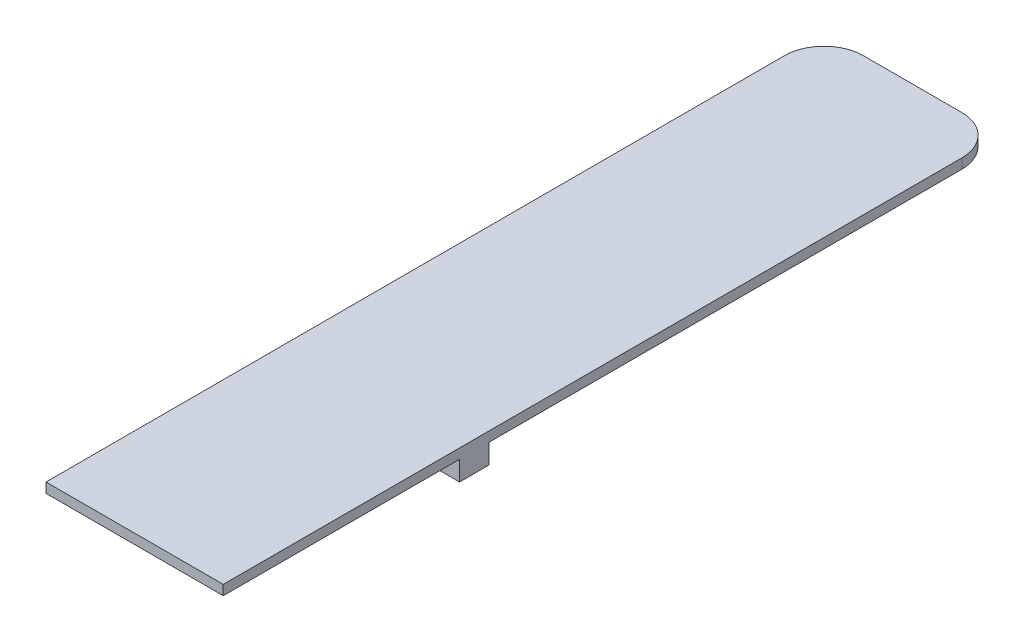
from build123d import *

# Parameters (mm, degrees)
SKETCH1_W           = 18
SKETCH1_H           = 55
BOSS_EXTRUDE1_DEPTH = 1
SKETCH2_W           = 18
SKETCH2_H           = 3
BOSS_EXTRUDE2_DEPTH = 2
SKETCH3_W           = 18
SKETCH3_H           = 1
BOSS_EXTRUDE3_DEPTH = 24
SKETCH4_W           = 7
SKETCH4_H           = 2
BOSS_EXTRUDE4_DEPTH = 2
FILLET1_R           = 4
BOSS_EXTRUDE5_DEPTH = 7


with BuildPart() as part:
    # Sketch1 → Boss-Extrude1 (new body)
    with BuildSketch(Plane(origin=(0, 0, 0), x_dir=(1, 0, 0), z_dir=(0, 1, 0))):
        with Locations((9, -27.5)):
            Rectangle(SKETCH1_W, SKETCH1_H)
    extrude(amount=BOSS_EXTRUDE1_DEPTH)

    # Sketch2 → Boss-Extrude2 (add)
    with BuildSketch(Plane.XZ):
        with Locations((9, 53.5)):
            Rectangle(SKETCH2_W, SKETCH2_H)
    extrude(amount=BOSS_EXTRUDE2_DEPTH)

    # Sketch3 → Boss-Extrude3 (add)
    with BuildSketch(Plane.XY.offset(55)):
        with Locations((9, 0.5)):
            Rectangle(SKETCH3_W, SKETCH3_H)
    extrude(amount=BOSS_EXTRUDE3_DEPTH)

    # Sketch4 → Boss-Extrude4 (add)
    with BuildSketch(Plane.XZ):
        with Locations((9, 6)):
            Rectangle(SKETCH4_W, SKETCH4_H)
    extrude(amount=BOSS_EXTRUDE4_DEPTH)

    # Fillet1
    fillet1_edges = [part.edges().sort_by_distance(p)[0] for p in [
        (0, 0.5, 0),
        (18, 0.5, 0),
    ]]
    fillet(fillet1_edges, radius=FILLET1_R)

    # Sketch5 → Boss-Extrude5 (add)
    with BuildSketch(Plane.ZY.offset(-5.5)):
        Polygon((7, 0), (7.615831877, -2), (7, -2), align=None)
        Polygon((5, 0), (5, -2), (4.384168123, 0), align=None)
    extrude(amount=-BOSS_EXTRUDE5_DEPTH)


solid = part.part
